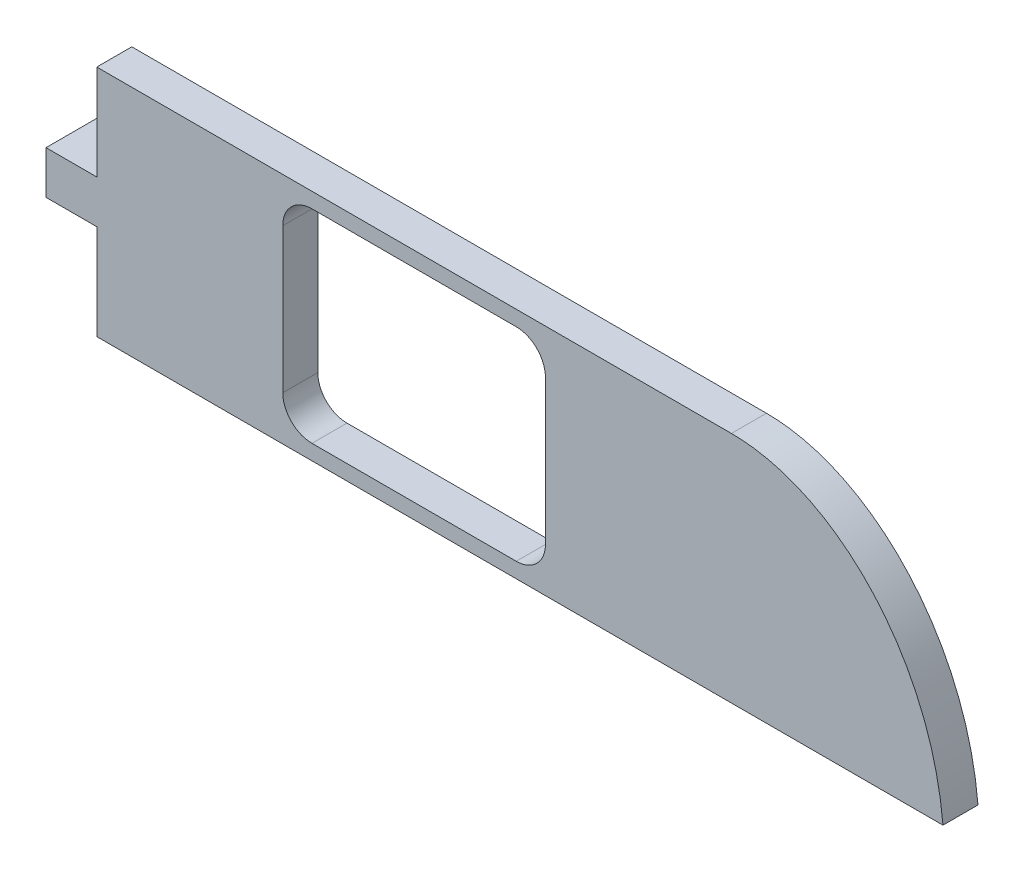
from build123d import *

# Parameters (mm, degrees)
CROQUIS1_W              = 4.5
CROQUIS1_H              = 3.47922044
SALIENTE_EXTRUIR1_DEPTH = 0.6
REDONDEO1_R             = 0.5
CROQUIS2_W              = 0.3
CROQUIS2_H              = 0.738230838
SALIENTE_EXTRUIR2_DEPTH = 0.8


with BuildPart() as part:
    # Croquis1 → Saliente-Extruir1 (new body)
    with BuildSketch(Plane.XY):
        with BuildLine():
            Line((-80.458731062, -26.409325636), (-69.586167188, -26.409325636))
            add(Edge.make_bspline(
                [(-69.586167188, -26.409325636), (-67.825300142, -26.409325636), (-66.171601872, -28.063804878), (-65.9618826, -30.409325636)],
                knots=[0, 0, 0, 0, 1, 1, 1, 1], degree=3))
            Line((-65.9618826, -30.409325636), (-69.586167188, -30.409325636))
            Line((-69.586167188, -30.409325636), (-80.458731062, -30.409325636))
            Line((-80.458731062, -30.409325636), (-80.458731062, -28.778441055))
            Line((-80.458731062, -28.778441055), (-81.328536172, -28.778441055))
            Line((-81.328536172, -28.778441055), (-81.328536172, -28.040210217))
            Line((-81.328536172, -28.040210217), (-80.458731062, -28.040210217))
            Line((-80.458731062, -28.040210217), (-80.458731062, -26.409325636))
        make_face()
        with Locations((-75.022449125, -28.409325636)):
            Rectangle(CROQUIS1_W, CROQUIS1_H, mode=Mode.SUBTRACT)
    extrude(amount=SALIENTE_EXTRUIR1_DEPTH)

    # Redondeo1
    redondeo1_edges = [part.edges().sort_by_distance(p)[0] for p in [
        (-77.272449125, -26.669715416, 0.3),
        (-77.272449125, -30.148935856, 0.3),
        (-72.772449125, -30.148935856, 0.3),
        (-72.772449125, -26.669715416, 0.3),
    ]]
    fillet(redondeo1_edges, radius=REDONDEO1_R)

    # Croquis2 → Saliente-Extruir2 (add)
    with BuildSketch(Plane(origin=(0, 0, 0), x_dir=(-1, 0, 0), z_dir=(0, 0, -1))):
        with Locations((81.178536172, -28.409325636)):
            Rectangle(CROQUIS2_W, CROQUIS2_H)
    extrude(amount=SALIENTE_EXTRUIR2_DEPTH)


solid = part.part
